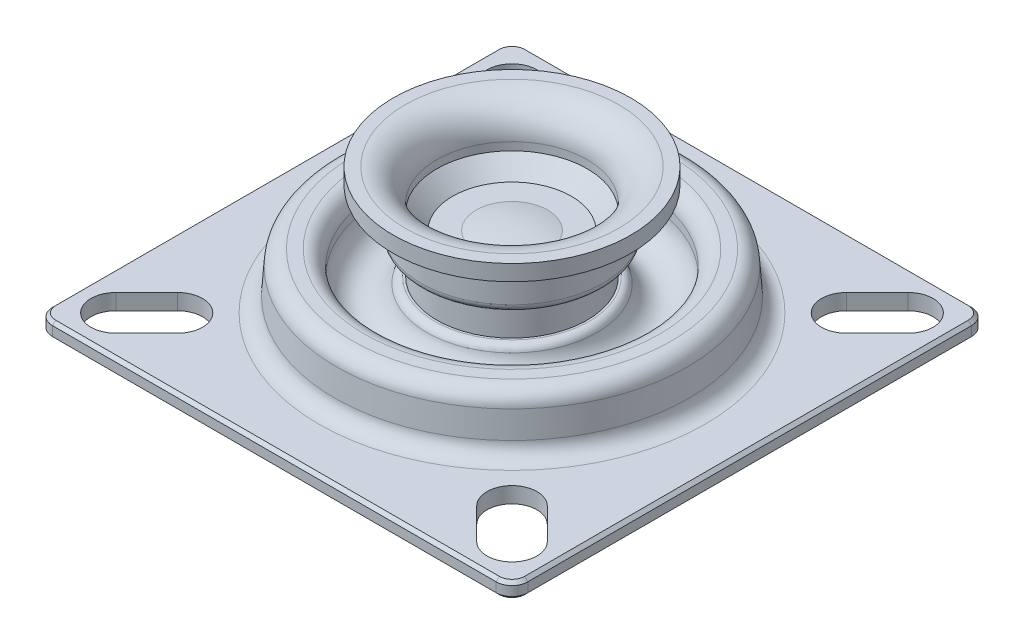
from build123d import *

# Parameters (mm, degrees)
ESQUISSE2_W        = 60
ESQUISSE2_H        = 60
BOSS_EXTRU_1_DEPTH = 1
CONG_1_R           = 5
ESQUISSE7_R        = 9.5
BOSS_EXTRU_2_DEPTH = 1
CONG_2_R           = 2
CONG_3_R           = 2
CHANFREIN1_SIZE    = 0.4


with BuildPart() as part:
    # Esquisse2 → Boss.-Extru.1 (new body, symmetric)
    with BuildSketch(Plane(origin=(0, 0, 0), x_dir=(1, 0, 0), z_dir=(0, 1, 0))):
        Rectangle(ESQUISSE2_W, ESQUISSE2_H)
        with BuildLine():
            Line((-22.772613639, 27.227386361), (-18.883526343, 23.338299064))
            ThreePointArc((-18.883526343, 23.338299064), (-18.883526343, 18.883526343), (-23.338299064, 18.883526343))
            Line((-23.338299064, 18.883526343), (-27.227386361, 22.772613639))
            ThreePointArc((-27.227386361, 22.772613639), (-27.227386361, 27.227386361), (-22.772613639, 27.227386361))
        make_face(mode=Mode.SUBTRACT)
        with BuildLine():
            Line((27.227386361, 22.772613639), (23.338299064, 18.883526343))
            ThreePointArc((23.338299064, 18.883526343), (18.883526343, 18.883526343), (18.883526343, 23.338299064))
            Line((18.883526343, 23.338299064), (22.772613639, 27.227386361))
            ThreePointArc((22.772613639, 27.227386361), (27.227386361, 27.227386361), (27.227386361, 22.772613639))
        make_face(mode=Mode.SUBTRACT)
        with BuildLine():
            Line((22.772613639, -27.227386361), (18.883526343, -23.338299064))
            ThreePointArc((18.883526343, -23.338299064), (18.883526343, -18.883526343), (23.338299064, -18.883526343))
            Line((23.338299064, -18.883526343), (27.227386361, -22.772613639))
            ThreePointArc((27.227386361, -22.772613639), (27.227386361, -27.227386361), (22.772613639, -27.227386361))
        make_face(mode=Mode.SUBTRACT)
        with BuildLine():
            Line((-27.227386361, -22.772613639), (-23.338299064, -18.883526343))
            ThreePointArc((-23.338299064, -18.883526343), (-18.883526343, -18.883526343), (-18.883526343, -23.338299064))
            Line((-18.883526343, -23.338299064), (-22.772613639, -27.227386361))
            ThreePointArc((-22.772613639, -27.227386361), (-27.227386361, -27.227386361), (-27.227386361, -22.772613639))
        make_face(mode=Mode.SUBTRACT)
    extrude(amount=BOSS_EXTRU_1_DEPTH, both=True)

    # Esquisse3 → Révolution1 (revolve)
    with BuildSketch(Plane.XY):
        with BuildLine():
            Line((22.5, 1), (22.132678993, 6.1424941))
            ThreePointArc((22.132678993, 6.1424941), (21.500665075, 7.463726101), (20.137761593, 8))
            Line((20.137761593, 8), (0, 8))
            Line((0, 8), (0, 1))
            Line((0, 1), (22.5, 1))
        make_face()
    revolve(axis=Axis((0, 8, 0), (0, -1, 0)))

    # Esquisse4 → Enlèvement de matière-Révolution1 (revolve, cut)
    with BuildSketch(Plane.XY):
        with BuildLine():
            Line((8.637761593, 2), (4.637761593, 2))
            Line((4.637761593, 2), (3.5, 3.137761593))
            Line((3.5, 3.137761593), (3.5, 6.5))
            Line((3.5, 6.5), (0, 6.5))
            Line((0, 6.5), (0, -2))
            Line((0, -2), (20.637761593, -2))
            Line((20.637761593, -2), (20.637761593, -1))
            Line((20.637761593, -1), (20.206467343, 5.038119503))
            ThreePointArc((20.206467343, 5.038119503), (19.136512804, 5.999341804), (18.137761593, 4.964331152))
            Line((18.137761593, 4.964331152), (18.137761593, 2))
            ThreePointArc((18.137761593, 2), (13.387761593, -1), (8.637761593, 2))
        make_face()
    revolve(axis=Axis((0, 6.5, 0), (0, -1, 0)), mode=Mode.SUBTRACT)

    # Congé1
    cong_1_edges = [part.edges().sort_by_distance(p)[0] for p in [
        (-20.637761593, -1, 0),
    ]]
    fillet(cong_1_edges, radius=CONG_1_R)

    # Esquisse5 → Enlèvement de matière-Révolution2 (revolve, cut)
    with BuildSketch(Plane.XY):
        with BuildLine():
            Line((16.637761593, 8), (16.637761593, 4.95))
            ThreePointArc((16.637761593, 4.95), (14.015774471, 1.973910911), (10.733024084, 4.2))
            ThreePointArc((10.733024084, 4.2), (10.377150683, 4.740569415), (9.764778247, 4.95))
            Line((9.764778247, 4.95), (9.5, 4.95))
            Line((9.5, 4.95), (9.5, 8))
            Line((9.5, 8), (16.637761593, 8))
        make_face()
    revolve(axis=Axis((0, 0, 0), (0, 1, 0)), mode=Mode.SUBTRACT)

    # Esquisse7 → Boss.-Extru.2 (add)
    with BuildSketch(Plane(origin=(0, 8, 0), x_dir=(1, 0, 0), z_dir=(0, 1, 0))):
        Circle(ESQUISSE7_R)
    extrude(amount=BOSS_EXTRU_2_DEPTH)

    # Congé2
    cong_2_edges = [part.edges().sort_by_distance(p)[0] for p in [
        (-16.637761593, 8, 0),
    ]]
    fillet(cong_2_edges, radius=CONG_2_R)

    # Esquisse6 → Révolution2 (revolve)
    with BuildSketch(Plane.XY):
        with BuildLine():
            Line((0, 10.5), (0, 9))
            Line((0, 9), (10.5, 9))
            ThreePointArc((10.5, 9), (11.207106781, 9.292893219), (11.5, 10))
            Line((11.5, 10), (11.5, 13))
            ThreePointArc((11.5, 13), (12.085786438, 14.414213562), (13.5, 15))
            Line((13.5, 15), (15, 15))
            Line((15, 15), (15, 17))
            Line((15, 17), (13.5, 17))
            ThreePointArc((13.5, 17), (10.671572875, 15.828427125), (9.5, 13))
            Line((9.5, 13), (9.5, 12))
            Line((9.5, 12), (7.5, 10))
            Line((7.5, 10), (4.5, 10))
            ThreePointArc((4.5, 10), (2.263846285, 10.374616561), (0, 10.5))
        make_face()
    revolve(axis=Axis((0, -1, 0), (0, 1, 0)))

    # Congé3
    cong_3_edges = [part.edges().sort_by_distance(p)[0] for p in [
        (-22.5, 1, 0),
        (30, 0, 30),
        (-30, 0, 30),
        (-30, 0, -30),
        (30, 0, -30),
    ]]
    fillet(cong_3_edges, radius=CONG_3_R)

    # Chanfrein1
    chanfrein1_edges = [part.edges().sort_by_distance(p)[0] for p in [
        (30, -1, 0),
        (30, 1, 0),
        (0, -1, 30),
        (-30, -1, 0),
        (0, -1, -30),
        (-29.414213562, -1, 29.414213562),
        (-29.414213562, -1, -29.414213562),
        (29.414213562, -1, -29.414213562),
        (29.414213562, -1, 29.414213562),
        (0, 1, 30),
        (0, 1, -30),
        (-30, 1, 0),
        (-29.414213562, 1, 29.414213562),
        (-29.414213562, 1, -29.414213562),
        (29.414213562, 1, -29.414213562),
        (29.414213562, 1, 29.414213562),
    ]]
    chamfer(chanfrein1_edges, length=CHANFREIN1_SIZE)


solid = part.part
